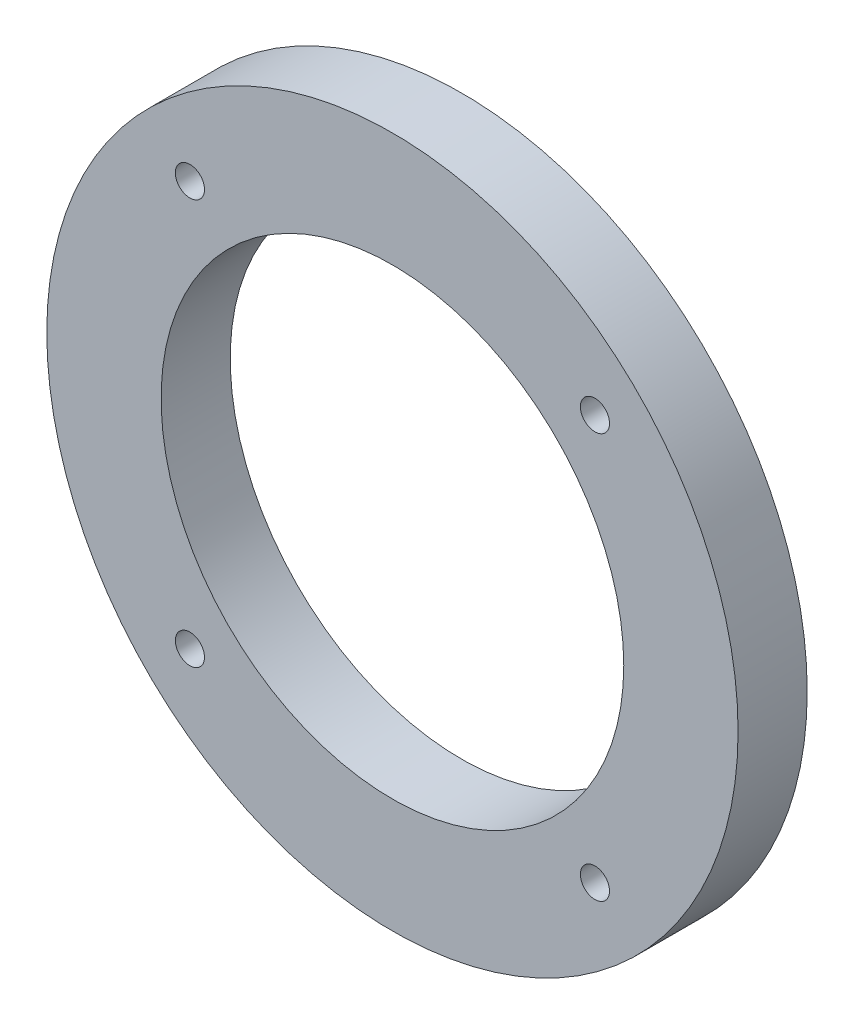
from build123d import *

# Parameters (mm, degrees)
SKETCH1_R           = 35
SKETCH1_R_2         = 23.425
SKETCH1_R_3         = 1.475
BOSS_EXTRUDE1_DEPTH = 7


with BuildPart() as part:
    # Sketch1 → Boss-Extrude1 (new body)
    with BuildSketch(Plane.XY):
        Circle(SKETCH1_R)
        Circle(SKETCH1_R_2, mode=Mode.SUBTRACT)
        with Locations((-20.506096654, 20.506096654)):
            Circle(SKETCH1_R_3, mode=Mode.SUBTRACT)
        with Locations((20.506096654, 20.506096654)):
            Circle(SKETCH1_R_3, mode=Mode.SUBTRACT)
        with Locations((20.506096654, -20.506096654)):
            Circle(SKETCH1_R_3, mode=Mode.SUBTRACT)
        with Locations((-20.506096654, -20.506096654)):
            Circle(SKETCH1_R_3, mode=Mode.SUBTRACT)
    extrude(amount=BOSS_EXTRUDE1_DEPTH)


solid = part.part
